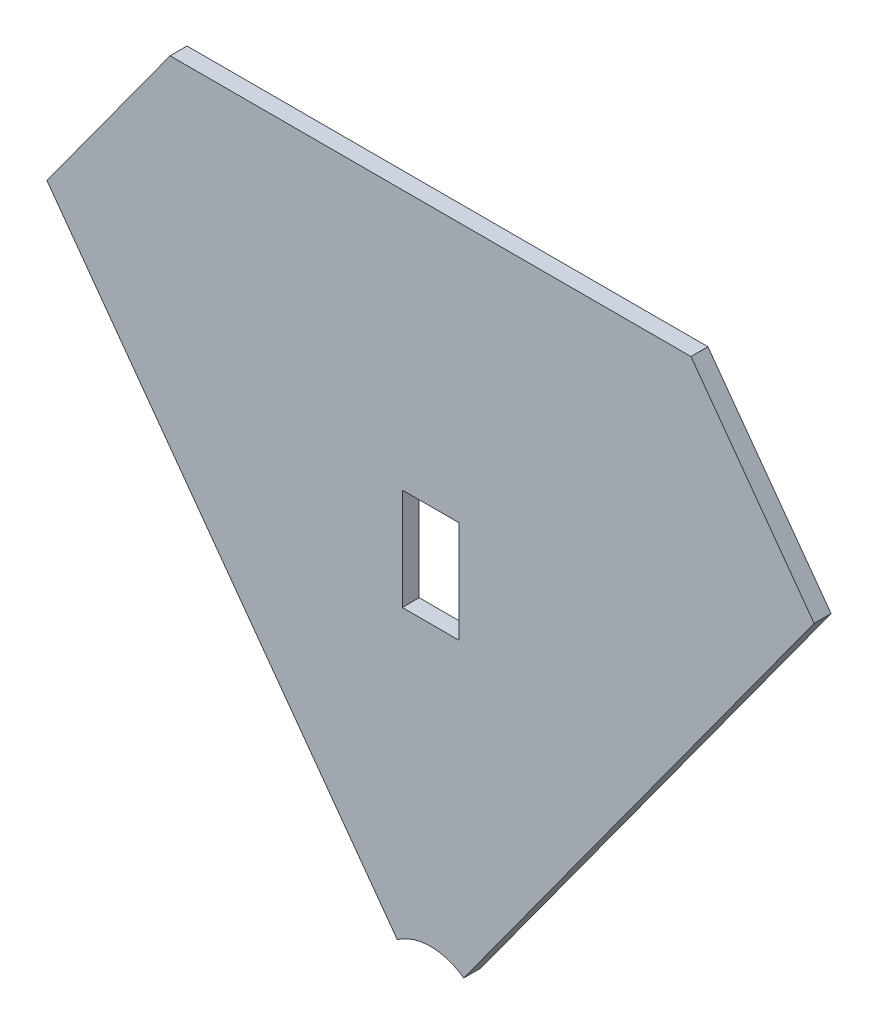
from build123d import *

# Parameters (mm, degrees)
SKETCH3_W           = 10
SKETCH3_H           = 18
BOSS_EXTRUDE1_DEPTH = 3
BOSS_EXTRUDE2_DEPTH = 3
CUT_EXTRUDE1_DEPTH  = 4
SKETCH6_R           = 10
CUT_EXTRUDE2_DEPTH  = 4


with BuildPart() as part:
    # Sketch3 → Boss-Extrude1 (new body)
    with BuildSketch(Plane.XY):
        Polygon((0, 0), (56.979097759, 78.425), (-56.979097759, 78.425), align=None)
        with Locations((0, 68.425)):
            Rectangle(SKETCH3_W, SKETCH3_H, mode=Mode.SUBTRACT)
    extrude(amount=BOSS_EXTRUDE1_DEPTH)

    # Sketch4 → Boss-Extrude2 (add)
    with BuildSketch(Plane(origin=(0, 0, 0), x_dir=(-1, 0, 0), z_dir=(0, 0, -1))):
        Polygon((-56.979097759, 78.425), (-89.673511519, 123.425), (89.673511519, 123.425), (56.979097759, 78.425), align=None)
    extrude(amount=-BOSS_EXTRUDE2_DEPTH)

    # Sketch5 → Cut-Extrude1 (cut, through all)
    with BuildSketch(Plane.XY.offset(3)):
        Polygon((-89.673511519, 123.425), (-46.080959839, 123.425), (-67.877235679, 93.425), align=None)
        Polygon((89.673511519, 123.425), (46.080959839, 123.425), (67.877235679, 93.425), align=None)
    extrude(amount=-CUT_EXTRUDE1_DEPTH, mode=Mode.SUBTRACT)

    # Sketch6 → Cut-Extrude2 (cut, through all)
    with BuildSketch(Plane(origin=(0, 0, 0), x_dir=(-1, 0, 0), z_dir=(0, 0, -1))):
        Circle(SKETCH6_R)
    extrude(amount=-CUT_EXTRUDE2_DEPTH, mode=Mode.SUBTRACT)


solid = part.part
